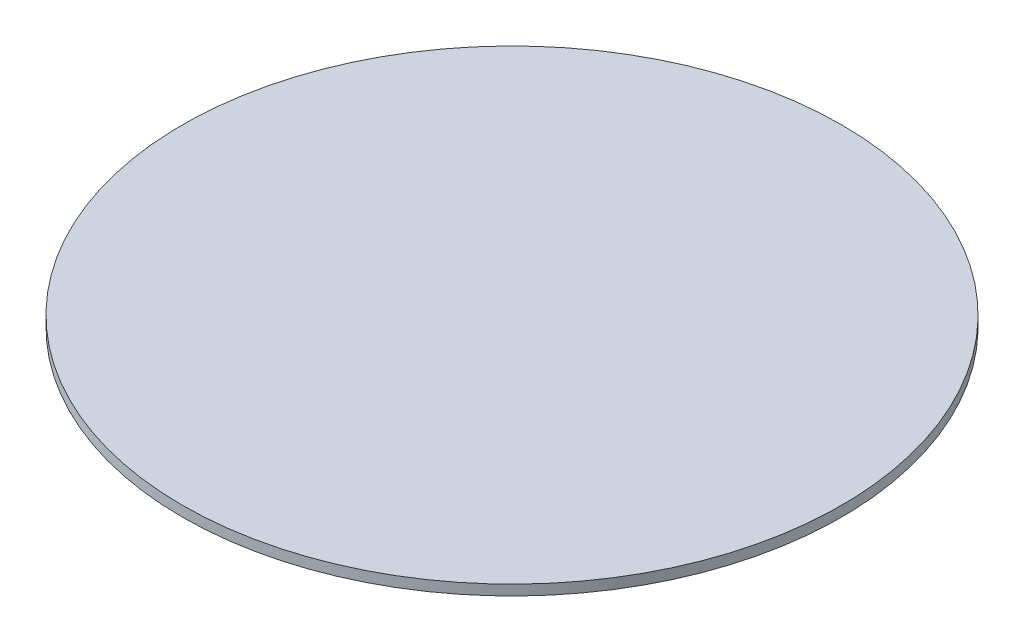
from build123d import *

# Parameters (mm, degrees)
SKETCH1_R           = 16
BOSS_EXTRUDE1_DEPTH = 0.5


with BuildPart() as part:
    # Sketch1 → Boss-Extrude1 (new body)
    with BuildSketch(Plane(origin=(0, 0, 0), x_dir=(1, 0, 0), z_dir=(0, 1, 0))):
        Circle(SKETCH1_R)
    extrude(amount=BOSS_EXTRUDE1_DEPTH)


solid = part.part
